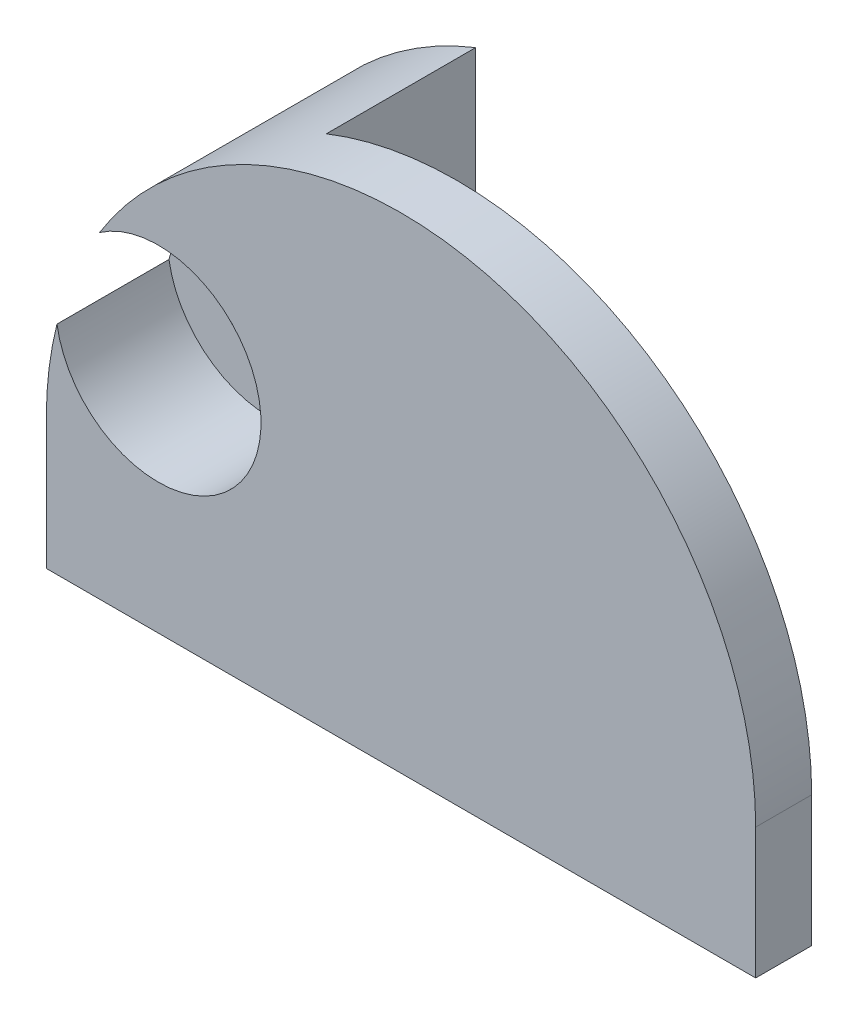
from build123d import *

# Parameters (mm, degrees)
ESBO_O1_R                = 1.5
RESSALTO_EXTRUS_O1_DEPTH = 5.5
ESBO_O2_W                = 13
ESBO_O2_H                = 14.546827215
CORTE_EXTRUS_O1_DEPTH    = 4
ESBO_O3_R                = 2.75
CORTE_EXTRUS_O2_DEPTH    = 3


with BuildPart() as part:
    # Esboço1 → Ressalto-extrusão1 (new body)
    with BuildSketch(Plane.XY):
        with BuildLine():
            Line((-9.5, 0), (-9.5, -3.5))
            Line((-9.5, -3.5), (9.5, -3.5))
            Line((9.5, -3.5), (9.5, 0))
            ThreePointArc((9.5, 0), (0, 9.5), (-9.5, 0))
        make_face()
        with Locations((-6.5, 2.75)):
            Circle(ESBO_O1_R, mode=Mode.SUBTRACT)
    extrude(amount=RESSALTO_EXTRUS_O1_DEPTH)

    # Esboço2 → Corte-extrusão1 (cut)
    with BuildSketch(Plane(origin=(0, 0, 0), x_dir=(-1, 0, 0), z_dir=(0, 0, -1))):
        with Locations((-3, 3.773413608)):
            Rectangle(ESBO_O2_W, ESBO_O2_H)
    extrude(amount=-CORTE_EXTRUS_O1_DEPTH, mode=Mode.SUBTRACT)

    # Esboço3 → Corte-extrusão2 (cut)
    with BuildSketch(Plane.XY.offset(5.5)):
        with Locations((-6.5, 2.75)):
            Circle(ESBO_O3_R)
    extrude(amount=-CORTE_EXTRUS_O2_DEPTH, mode=Mode.SUBTRACT)


solid = part.part
